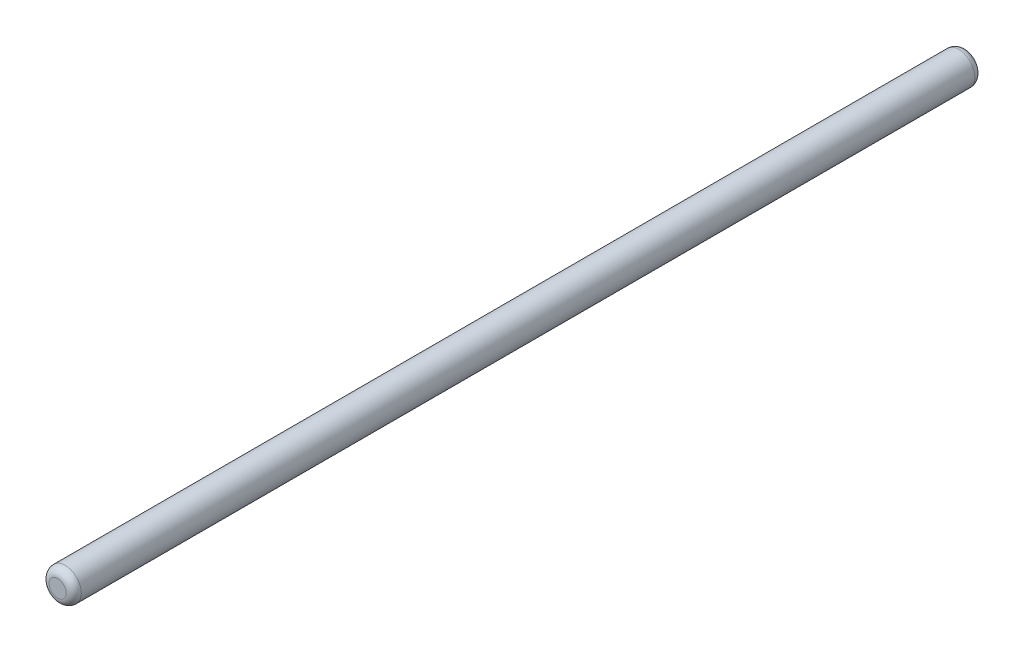
from build123d import *

# Parameters (mm, degrees)
SKETCH1_R           = 4.25
BOSS_EXTRUDE1_DEPTH = 120
FILLET1_R           = 2


with BuildPart() as part:
    # Sketch1 → Boss-Extrude1 (new body, symmetric)
    with BuildSketch(Plane.XY):
        Circle(SKETCH1_R)
    extrude(amount=BOSS_EXTRUDE1_DEPTH, both=True)

    # Fillet1
    fillet1_edges = [part.edges().sort_by_distance(p)[0] for p in [
        (-4.25, 0, -120),
        (-4.25, 0, 120),
    ]]
    fillet(fillet1_edges, radius=FILLET1_R)


solid = part.part
